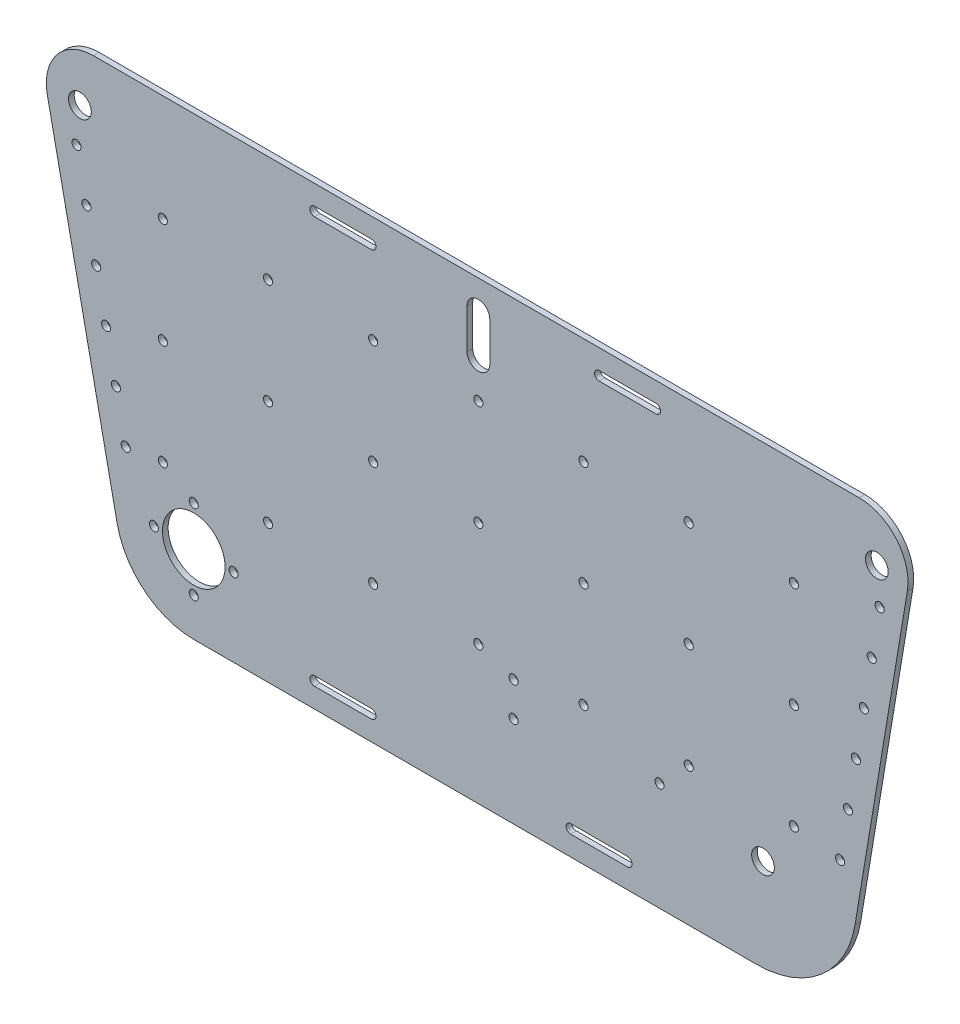
from build123d import *

# Parameters (mm, degrees)
SKETCH3_R           = 1.6
SKETCH3_R_2         = 11
SKETCH3_R_3         = 4
BOSS_EXTRUDE1_DEPTH = 2
CUT_EXTRUDE3_DEPTH  = 3
SKETCH7_R           = 1.6
CUT_EXTRUDE4_DEPTH  = 3


with BuildPart() as part:
    # Sketch3 → Boss-Extrude1 (new body)
    with BuildSketch(Plane.XY):
        with BuildLine():
            ThreePointArc((-151.456383586, 112.587537538), (-148.084116861, 126.418210974), (-135.227817714, 132.531743734))
            Line((-135.227817714, 132.531743734), (133.810342842, 132.531743734))
            ThreePointArc((133.810342842, 132.531743734), (146.883625567, 126.475757693), (150.718078468, 112.587537538))
            Line((150.718078468, 112.587537538), (132.342869895, 1.839758932))
            ThreePointArc((132.342869895, 1.839758932), (120.43275171, -19.155269629), (97.771410342, -27.468256266))
            Line((97.771410342, -27.468256266), (-100, -27.468256266))
            ThreePointArc((-100, -27.468256266), (-117.356688592, -21.298876537), (-126.925740619, -5.558827984))
            Line((-126.925740619, -5.558827984), (-151.456383586, 112.587537538))
        make_face()
        with Locations((-114, 0.031743734)):
            Circle(SKETCH3_R, mode=Mode.SUBTRACT)
        with Locations((-100, -13.968256266)):
            Circle(SKETCH3_R, mode=Mode.SUBTRACT)
        with Locations((-86, 0.031743734)):
            Circle(SKETCH3_R, mode=Mode.SUBTRACT)
        with Locations((-100, 14.031743734)):
            Circle(SKETCH3_R, mode=Mode.SUBTRACT)
        with Locations((12.357913989, 16.531743734)):
            Circle(SKETCH3_R, mode=Mode.SUBTRACT)
        with Locations((12.357913989, 4.531743734)):
            Circle(SKETCH3_R, mode=Mode.SUBTRACT)
        with Locations((63.65613527, 10.531743734)):
            Circle(SKETCH3_R, mode=Mode.SUBTRACT)
        with Locations((-100, 0.031743734)):
            Circle(SKETCH3_R_2, mode=Mode.SUBTRACT)
        with Locations((100, 5.031743734)):
            Circle(SKETCH3_R_3, mode=Mode.SUBTRACT)
        with Locations((140, 115.061965544)):
            Circle(SKETCH3_R_3, mode=Mode.SUBTRACT)
        with Locations((-140, 115.061965544)):
            Circle(SKETCH3_R_3, mode=Mode.SUBTRACT)
        with BuildLine():
            ThreePointArc((-4, 108.133762314), (0, 104.133762314), (4, 108.133762314))
            Line((4, 108.133762314), (4, 121.990168775))
            ThreePointArc((4, 121.990168775), (0, 125.990168775), (-4, 121.990168775))
            Line((-4, 121.990168775), (-4, 108.133762314))
        make_face(mode=Mode.SUBTRACT)
    extrude(amount=BOSS_EXTRUDE1_DEPTH)

    # Sketch6 → Cut-Extrude3 (cut, through all)
    with BuildSketch(Plane.XY):
        with BuildLine():
            Line((-57.58, -17.298256266), (-37.58, -17.298256266))
            ThreePointArc((-37.58, -17.298256266), (-35.98, -18.898256266), (-37.58, -20.498256266))
            Line((-37.58, -20.498256266), (-57.58, -20.498256266))
            ThreePointArc((-57.58, -20.498256266), (-59.18, -18.898256266), (-57.58, -17.298256266))
        make_face()
        with BuildLine():
            Line((32.42, -17.298256266), (52.42, -17.298256266))
            ThreePointArc((52.42, -17.298256266), (54.02, -18.898256266), (52.42, -20.498256266))
            Line((52.42, -20.498256266), (32.42, -20.498256266))
            ThreePointArc((32.42, -20.498256266), (30.82, -18.898256266), (32.42, -17.298256266))
        make_face()
        with BuildLine():
            Line((-57.58, 125.561743734), (-37.58, 125.561743734))
            ThreePointArc((-37.58, 125.561743734), (-35.98, 123.961743734), (-37.58, 122.361743734))
            Line((-37.58, 122.361743734), (-57.58, 122.361743734))
            ThreePointArc((-57.58, 122.361743734), (-59.18, 123.961743734), (-57.58, 125.561743734))
        make_face()
        with BuildLine():
            Line((42.42, 125.561743734), (62.42, 125.561743734))
            ThreePointArc((62.42, 125.561743734), (64.02, 123.961743734), (62.42, 122.361743734))
            Line((62.42, 122.361743734), (42.42, 122.361743734))
            ThreePointArc((42.42, 122.361743734), (40.82, 123.961743734), (42.42, 125.561743734))
        make_face()
    extrude(amount=CUT_EXTRUDE3_DEPTH, mode=Mode.SUBTRACT)

    # Sketch7 → Cut-Extrude4 (cut, through all)
    with BuildSketch(Plane.XY.offset(2)):
        with Locations((-110.862196782, 95.074335332)):
            Circle(SKETCH7_R)
        with Locations((-73.908131188, 95.074335332)):
            Circle(SKETCH7_R)
        with Locations((-36.954065594, 95.074335332)):
            Circle(SKETCH7_R)
        with Locations((0, 95.074335332)):
            Circle(SKETCH7_R)
        with Locations((36.954065594, 95.074335332)):
            Circle(SKETCH7_R)
        with Locations((73.908131188, 95.074335332)):
            Circle(SKETCH7_R)
        with Locations((110.862196782, 95.074335332)):
            Circle(SKETCH7_R)
        with Locations((-73.908131188, 58.074335332)):
            Circle(SKETCH7_R)
        with Locations((-36.954065594, 58.074335332)):
            Circle(SKETCH7_R)
        with Locations((0, 58.074335332)):
            Circle(SKETCH7_R)
        with Locations((36.954065594, 58.074335332)):
            Circle(SKETCH7_R)
        with Locations((73.908131188, 58.074335332)):
            Circle(SKETCH7_R)
        with Locations((110.862196782, 58.074335332)):
            Circle(SKETCH7_R)
        with Locations((-73.908131188, 21.074335332)):
            Circle(SKETCH7_R)
        with Locations((-36.954065594, 21.074335332)):
            Circle(SKETCH7_R)
        with Locations((0, 21.074335332)):
            Circle(SKETCH7_R)
        with Locations((36.954065594, 21.074335332)):
            Circle(SKETCH7_R)
        with Locations((73.908131188, 21.074335332)):
            Circle(SKETCH7_R)
        with Locations((110.862196782, 21.074335332)):
            Circle(SKETCH7_R)
        with Locations((-110.862196782, 58.074335332)):
            Circle(SKETCH7_R)
        with Locations((-110.862196782, 21.074335332)):
            Circle(SKETCH7_R)
        with Locations((-141.184392471, 102.466753609)):
            Circle(SKETCH7_R)
        with Locations((-137.728402681, 85.821750317)):
            Circle(SKETCH7_R)
        with Locations((-134.272412891, 69.176747026)):
            Circle(SKETCH7_R)
        with Locations((-130.816423102, 52.531743734)):
            Circle(SKETCH7_R)
        with Locations((-127.360433312, 35.886740443)):
            Circle(SKETCH7_R)
        with Locations((-123.904443522, 19.241737151)):
            Circle(SKETCH7_R)
        with Locations((140.992053056, 102.843917034)):
            Circle(SKETCH7_R)
        with Locations((138.209463976, 86.0731926)):
            Circle(SKETCH7_R)
        with Locations((135.426874896, 69.302468167)):
            Circle(SKETCH7_R)
        with Locations((132.644285816, 52.531743734)):
            Circle(SKETCH7_R)
        with Locations((129.861696736, 35.761019301)):
            Circle(SKETCH7_R)
        with Locations((127.079107656, 18.990294868)):
            Circle(SKETCH7_R)
    extrude(amount=-CUT_EXTRUDE4_DEPTH, mode=Mode.SUBTRACT)


solid = part.part
